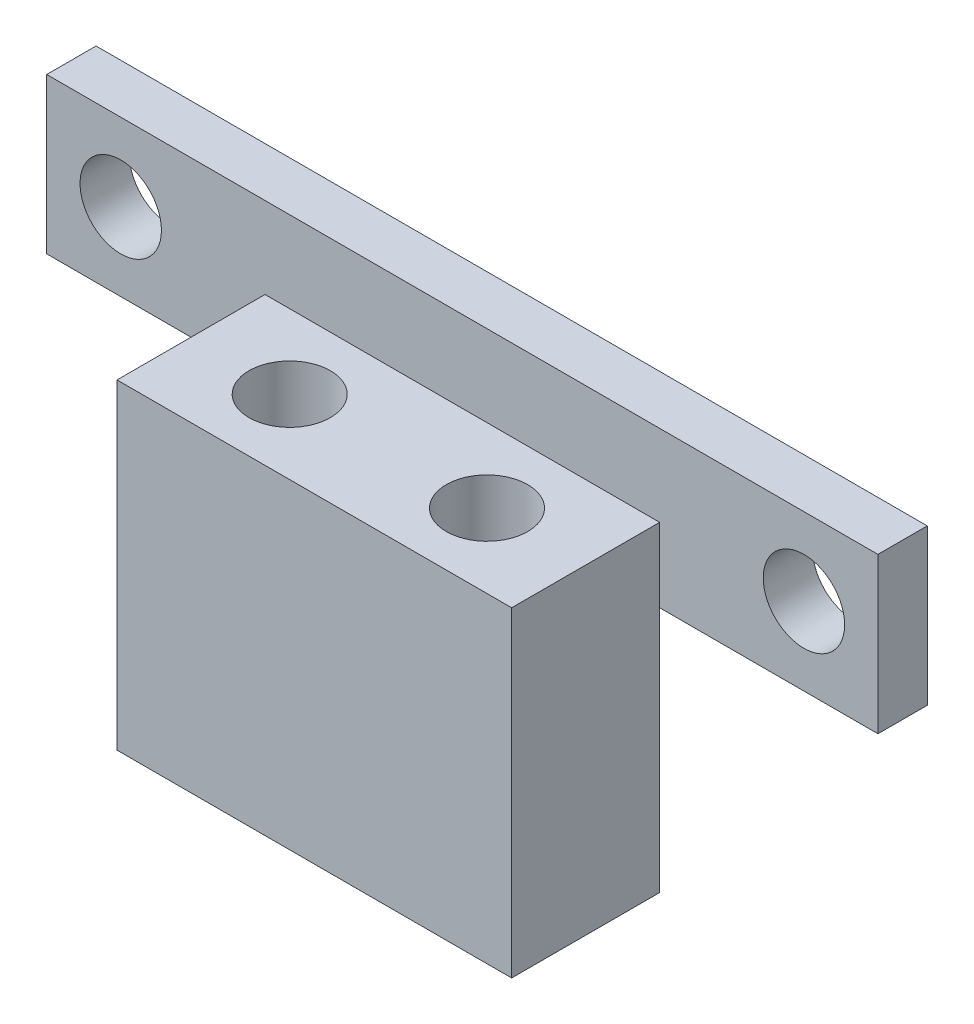
from build123d import *

# Parameters (mm, degrees)
SKETCH1_W           = 33.7
SKETCH1_H           = 6.3
SKETCH1_R           = 1.65
BOSS_EXTRUDE1_DEPTH = 2
SKETCH2_W           = 16
SKETCH2_H           = 3
BOSS_EXTRUDE2_DEPTH = 6
SKETCH3_R           = 1.65
CUT_EXTRUDE1_DEPTH  = 6
SKETCH4_W           = 16
SKETCH4_H           = 6
SKETCH4_R           = 1.65
BOSS_EXTRUDE3_DEPTH = 10


with BuildPart() as part:
    # Sketch1 → Boss-Extrude1 (new body)
    with BuildSketch(Plane.XY):
        with Locations((16.85, 3.15)):
            Rectangle(SKETCH1_W, SKETCH1_H)
        with Locations((3, 3.15)):
            Circle(SKETCH1_R, mode=Mode.SUBTRACT)
        with Locations((30.7, 3.15)):
            Circle(SKETCH1_R, mode=Mode.SUBTRACT)
    extrude(amount=BOSS_EXTRUDE1_DEPTH)

    # Sketch2 → Boss-Extrude2 (add)
    with BuildSketch(Plane.XY.offset(2)):
        with Locations((16.85, 1.5)):
            Rectangle(SKETCH2_W, SKETCH2_H)
    extrude(amount=BOSS_EXTRUDE2_DEPTH)

    # Sketch3 → Cut-Extrude1 (cut)
    with BuildSketch(Plane(origin=(0, 3, 0), x_dir=(1, 0, 0), z_dir=(0, 1, 0))):
        with Locations((12.85, -5)):
            Circle(SKETCH3_R)
        with Locations((20.85, -5)):
            Circle(SKETCH3_R)
    extrude(amount=-CUT_EXTRUDE1_DEPTH, mode=Mode.SUBTRACT)

    # Sketch4 → Boss-Extrude3 (add)
    with BuildSketch(Plane.XZ):
        with Locations((16.85, 5)):
            Rectangle(SKETCH4_W, SKETCH4_H)
        with Locations((12.85, 5)):
            Circle(SKETCH4_R, mode=Mode.SUBTRACT)
        with Locations((20.85, 5)):
            Circle(SKETCH4_R, mode=Mode.SUBTRACT)
    extrude(amount=BOSS_EXTRUDE3_DEPTH)


solid = part.part
